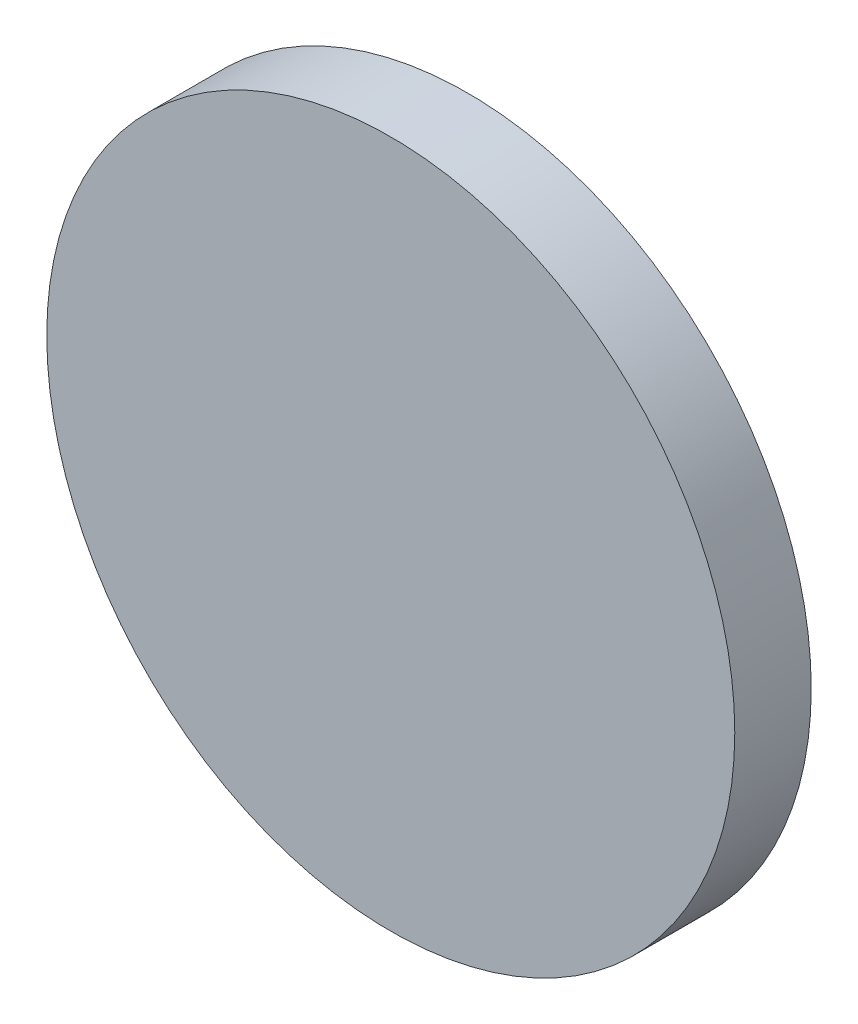
from build123d import *

# Parameters (mm, degrees)
SKETCH1_R           = 9
BOSS_EXTRUDE1_DEPTH = 2


with BuildPart() as part:
    # Sketch1 → Boss-Extrude1 (new body)
    with BuildSketch(Plane.XY):
        Circle(SKETCH1_R)
    extrude(amount=BOSS_EXTRUDE1_DEPTH)


solid = part.part
